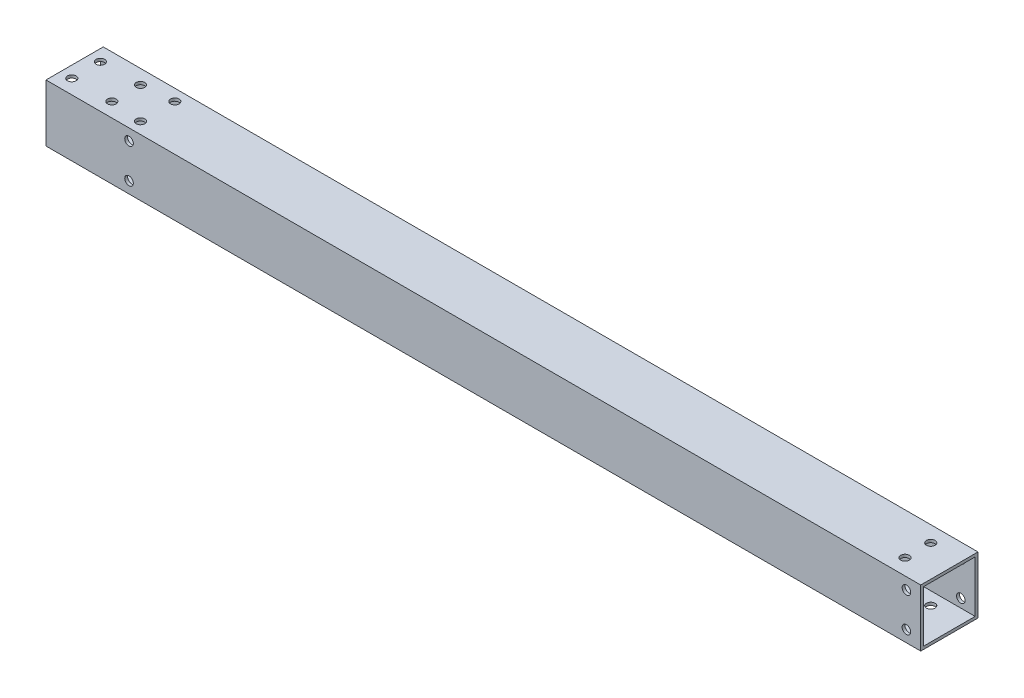
from build123d import *

# Parameters (mm, degrees)
SKETCH_11_W         = 20
SKETCH_11_H         = 20
SKETCH_11_W_2       = 18
SKETCH_11_H_2       = 18
F_20X20X1_1_DEPTH   = 305.54
SKETCH_16_R         = 1.5
CUT_EXTRUDE_3_DEPTH = 307.357130813
SKETCH_18_R         = 1.5
CUT_EXTRUDE_5_DEPTH = 307.357130813
SKETCH_14_R         = 1.5
CUT_EXTRUDE_6_DEPTH = 20
SKETCH_17_R         = 1.5
CUT_EXTRUDE_7_DEPTH = 20
SKETCH_15_R         = 1.5
CUT_EXTRUDE_8_DEPTH = 20


with BuildPart() as part:
    # 草图11 → 铝管 20X20X1(1) (new body)
    with BuildSketch(Plane(origin=(0, 0, 0), x_dir=(0, 0, -1), z_dir=(1, 0, 0))):
        Rectangle(SKETCH_11_W, SKETCH_11_H)
        Rectangle(SKETCH_11_W_2, SKETCH_11_H_2, mode=Mode.SUBTRACT)
    extrude(amount=F_20X20X1_1_DEPTH)

    # 草图16 → 切除-拉伸3 (cut, through all)
    with BuildSketch(Plane(origin=(0, 0, 10), x_dir=(1, 0, 0), z_dir=(0, 0, -1))):
        with Locations(Location((29, -6, 0), (0, 0, 180))):
            Circle(SKETCH_16_R)
        with Locations(Location((29, 6, 0), (0, 0, 180))):
            Circle(SKETCH_16_R)
    extrude(amount=CUT_EXTRUDE_3_DEPTH, mode=Mode.SUBTRACT)

    # 草图18 → 切除-拉伸5 (cut, through all)
    with BuildSketch(Plane(origin=(0, 10, 0), x_dir=(1, 0, 0), z_dir=(0, 1, 0))):
        with Locations(Location((29, 6, 0), (0, 0, 270))):
            Circle(SKETCH_18_R)
        with Locations(Location((29, -6, 0), (0, 0, 270))):
            Circle(SKETCH_18_R)
    extrude(amount=-CUT_EXTRUDE_5_DEPTH, mode=Mode.SUBTRACT)

    # 草图14 → 切除-拉伸6 (cut)
    with BuildSketch(Plane(origin=(0, 10, 0), x_dir=(1, 0, 0), z_dir=(0, 1, 0))):
        with Locations(Location((294.54, 4.5, 0), (0, 0, 270))):
            Circle(SKETCH_14_R)
        with Locations(Location((294.54, -4.5, 0), (0, 0, 270))):
            Circle(SKETCH_14_R)
    extrude(amount=-CUT_EXTRUDE_6_DEPTH, mode=Mode.SUBTRACT)

    # 草图17 → 切除-拉伸7 (cut)
    with BuildSketch(Plane(origin=(0, 0, -10), x_dir=(-1, 0, 0), z_dir=(0, 0, -1))):
        with Locations((-300.54, 6)):
            Circle(SKETCH_17_R)
        with Locations((-300.54, -6)):
            Circle(SKETCH_17_R)
    extrude(amount=-CUT_EXTRUDE_7_DEPTH, mode=Mode.SUBTRACT)

    # 草图15 → 切除-拉伸8 (cut)
    with BuildSketch(Plane(origin=(0, 10, 0), x_dir=(1, 0, 0), z_dir=(0, 1, 0))):
        with Locations(Location((4, 5, 0), (0, 0, 270))):
            Circle(SKETCH_15_R)
        with Locations(Location((4, -5, 0), (0, 0, 270))):
            Circle(SKETCH_15_R)
        with Locations(Location((18, 5, 0), (0, 0, 270))):
            Circle(SKETCH_15_R)
        with Locations(Location((18, -5, 0), (0, 0, 270))):
            Circle(SKETCH_15_R)
    extrude(amount=-CUT_EXTRUDE_8_DEPTH, mode=Mode.SUBTRACT)


solid = part.part
